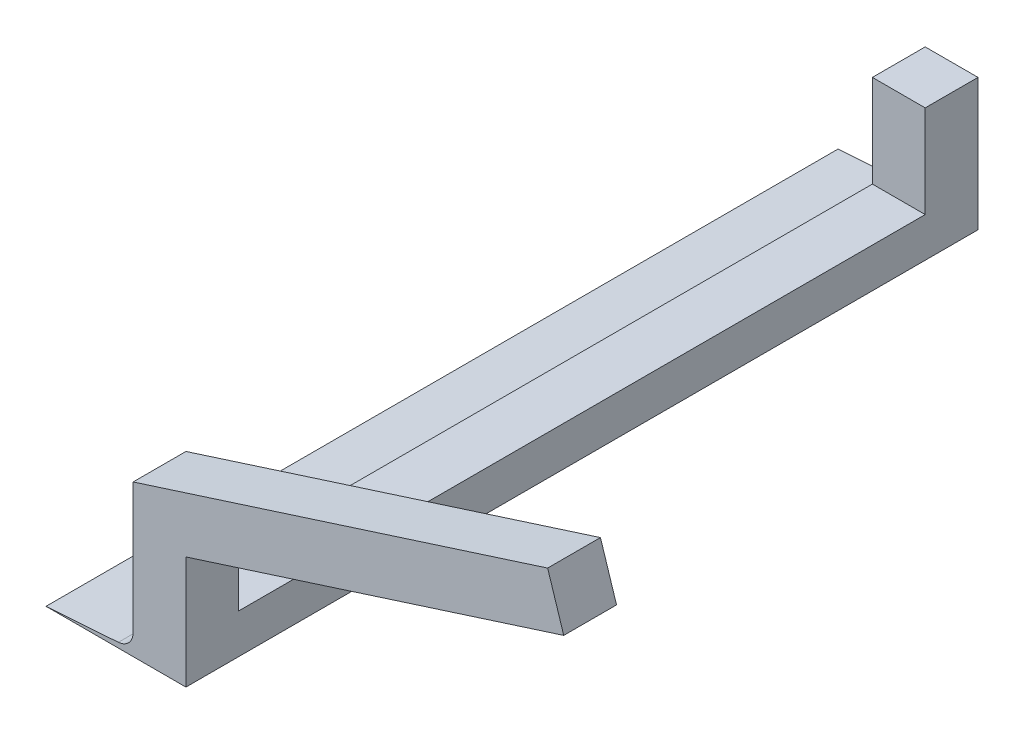
from build123d import *

# Parameters (mm, degrees)
BOSS_EXTRU_2_DEPTH = 300
ESQUISSE7_W        = 20
ESQUISSE7_H        = 20
BOSS_EXTRU_5_DEPTH = 35
BOSS_EXTRU_6_DEPTH = 20


with BuildPart() as part:
    # Esquisse2 → Boss.-Extru.2 (new body)
    with BuildSketch(Plane.XY):
        Polygon((18, 15), (18, 0), (0, 0), (0, 5.028017638), (0, 15), align=None)
        with BuildLine():
            Line((-2, 15), (-2, 7.892441846))
            ThreePointArc((-2, 7.892441846), (-3.612637831, 3.799636794), (-7.583684398, 1.906902495))
            Line((-7.583684398, 1.906902495), (-35, 0))
            Line((-35, 0), (0, 0))
            Line((0, 0), (0, 5.028017638))
            Line((0, 5.028017638), (0, 15))
            Line((0, 15), (-2, 15))
        make_face()
    extrude(amount=BOSS_EXTRU_2_DEPTH)

    # Esquisse7 → Boss.-Extru.5 (add)
    with BuildSketch(Plane(origin=(0, 15, 0), x_dir=(1, 0, 0), z_dir=(0, 1, 0))):
        with Locations((8, -10)):
            Rectangle(ESQUISSE7_W, ESQUISSE7_H)
        with Locations((8, -290)):
            Rectangle(ESQUISSE7_W, ESQUISSE7_H)
    extrude(amount=BOSS_EXTRU_5_DEPTH)

    # Esquisse8 → Boss.-Extru.6 (add)
    with BuildSketch(Plane.XY.offset(300)):
        Polygon((158.049218198, 98.031133425), (155.000575208, 107.555091421), (-2, 57.298811074), (-2, 36.299138452), (161.097861189, 88.507175428), align=None)
    extrude(amount=-BOSS_EXTRU_6_DEPTH)


solid = part.part
